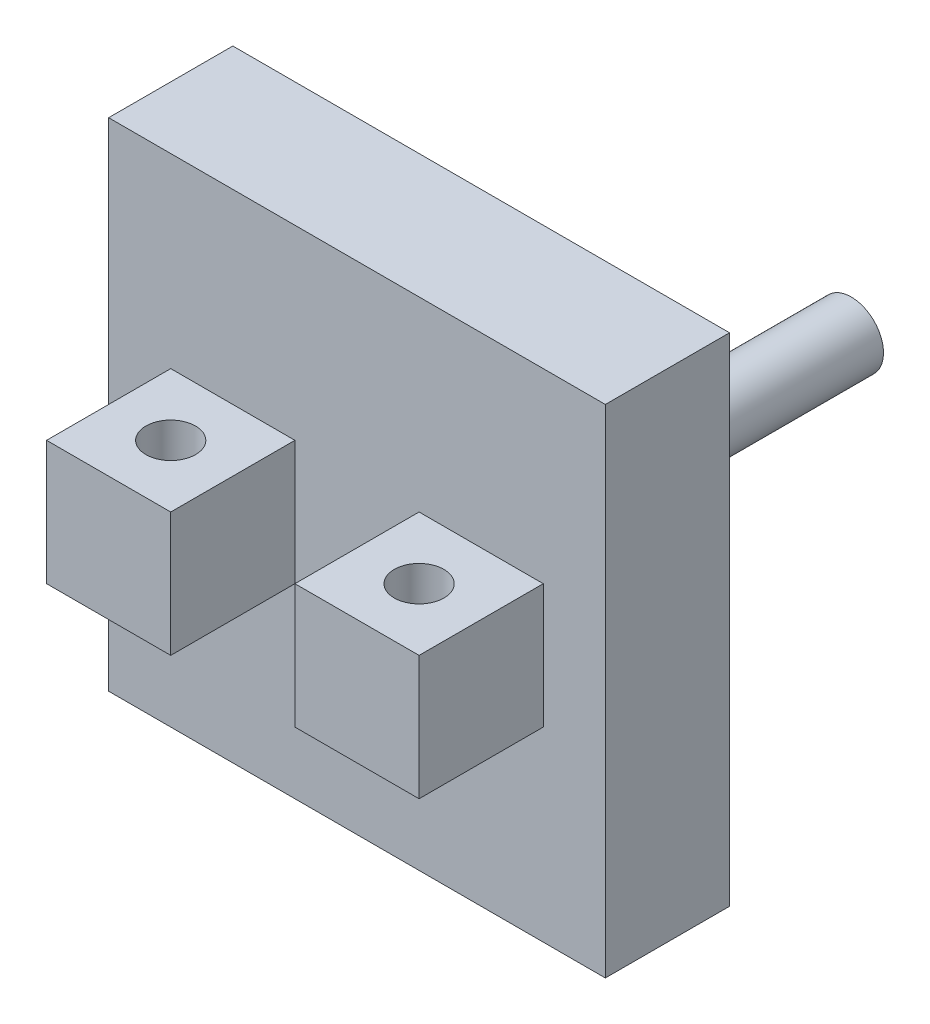
from build123d import *

# Parameters (mm, degrees)
BOSS_EXTRUDE1_DEPTH = 50
SKETCH3_R           = 10
CUT_EXTRUDE1_DEPTH  = 50
SKETCH4_W           = 150
SKETCH4_H           = 50
BOSS_EXTRUDE2_DEPTH = 50
SKETCH5_W           = 150
SKETCH5_H           = 50
BOSS_EXTRUDE3_DEPTH = 50
SKETCH6_W           = 200
SKETCH6_H           = 200
SKETCH6_W_2         = 150
SKETCH6_H_2         = 150
BOSS_EXTRUDE4_DEPTH = 50
SKETCH7_R           = 32
BOSS_EXTRUDE5_DEPTH = 12
SKETCH8_R           = 13
BOSS_EXTRUDE6_DEPTH = 112


with BuildPart() as part:
    # Sketch2 → Boss-Extrude1 (new body)
    with BuildSketch(Plane(origin=(0, 0, 0), x_dir=(1, 0, 0), z_dir=(0, 1, 0))):
        Polygon((0, 100), (0, 0), (50, 0), (50, 50), (100, 50), (100, 0), (150, 0), (150, 100), align=None)
    extrude(amount=BOSS_EXTRUDE1_DEPTH)

    # Sketch3 → Cut-Extrude1 (cut)
    with BuildSketch(Plane(origin=(0, 50, 0), x_dir=(1, 0, 0), z_dir=(0, 1, 0))):
        with Locations((125, 25)):
            Circle(SKETCH3_R)
        with Locations((25, 25)):
            Circle(SKETCH3_R)
    extrude(amount=-CUT_EXTRUDE1_DEPTH, mode=Mode.SUBTRACT)

    # Sketch4 → Boss-Extrude2 (add)
    with BuildSketch(Plane(origin=(0, 50, 0), x_dir=(1, 0, 0), z_dir=(0, 1, 0))):
        with Locations((75, 75)):
            Rectangle(SKETCH4_W, SKETCH4_H)
    extrude(amount=BOSS_EXTRUDE2_DEPTH)

    # Sketch5 → Boss-Extrude3 (add)
    with BuildSketch(Plane.XZ):
        with Locations((75, -75)):
            Rectangle(SKETCH5_W, SKETCH5_H)
    extrude(amount=BOSS_EXTRUDE3_DEPTH)

    # Sketch6 → Boss-Extrude4 (add)
    with BuildSketch(Plane(origin=(0, 0, -100), x_dir=(-1, 0, 0), z_dir=(0, 0, -1))):
        with Locations((-75, 25)):
            Rectangle(SKETCH6_W, SKETCH6_H)
        with Locations((-75, 25)):
            Rectangle(SKETCH6_W_2, SKETCH6_H_2, mode=Mode.SUBTRACT)
    extrude(amount=-BOSS_EXTRUDE4_DEPTH)

    # Sketch7 → Boss-Extrude5 (add)
    with BuildSketch(Plane(origin=(0, 0, -100), x_dir=(-1, 0, 0), z_dir=(0, 0, -1))):
        with Locations((-100, 25)):
            Circle(SKETCH7_R)
    extrude(amount=BOSS_EXTRUDE5_DEPTH)

    # Sketch8 → Boss-Extrude6 (add)
    with BuildSketch(Plane(origin=(0, 0, -112), x_dir=(-1, 0, 0), z_dir=(0, 0, -1))):
        with Locations((-100, 25)):
            Circle(SKETCH8_R)
    extrude(amount=BOSS_EXTRUDE6_DEPTH)


solid = part.part
